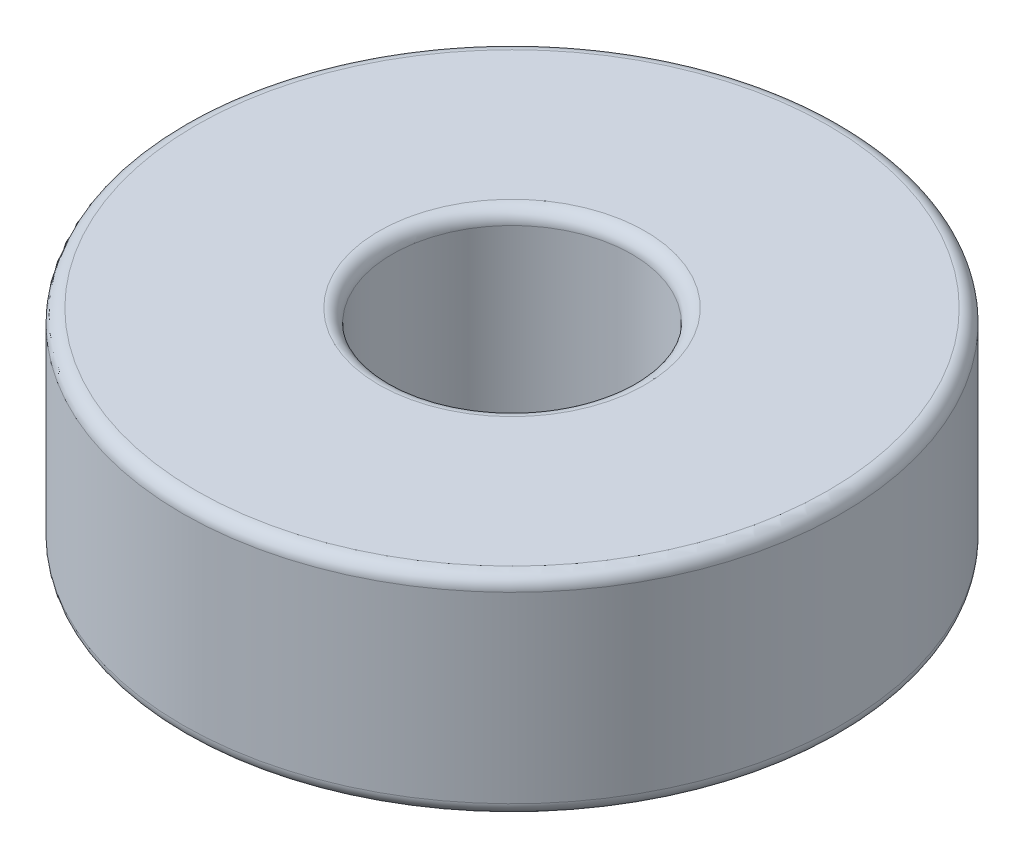
from build123d import *

# Parameters (mm, degrees)
SKETCH1_R           = 11
SKETCH1_R_2         = 4
BOSS_EXTRUDE1_DEPTH = 7
FILLET1_R           = 0.4445


with BuildPart() as part:
    # Sketch1 → Boss-Extrude1 (new body)
    with BuildSketch(Plane(origin=(0, 0, 0), x_dir=(1, 0, 0), z_dir=(0, 1, 0))):
        Circle(SKETCH1_R)
        Circle(SKETCH1_R_2, mode=Mode.SUBTRACT)
    extrude(amount=BOSS_EXTRUDE1_DEPTH)

    # Fillet1
    fillet1_edges = [part.edges().sort_by_distance(p)[0] for p in [
        (-11, 0, 0),
        (-11, 7, 0),
        (-4, 0, 0),
        (-4, 7, 0),
    ]]
    fillet(fillet1_edges, radius=FILLET1_R)


solid = part.part
